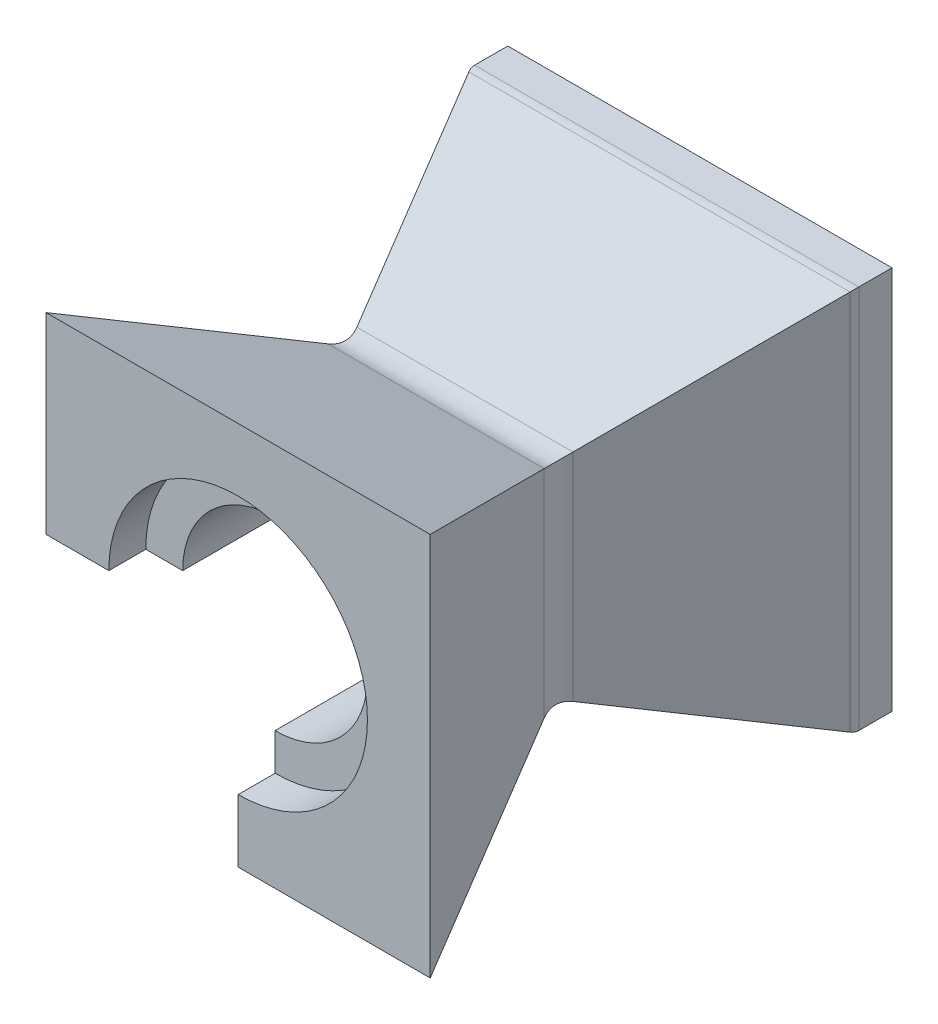
from build123d import *

# Parameters (mm, degrees)
SKETCH1_W           = 104
SKETCH1_H           = 104
SKETCH1_R           = 25
BOSS_EXTRUDE1_DEPTH = 115
CUT_EXTRUDE3_DEPTH  = 115
CUT_EXTRUDE4_DEPTH  = 115
CUT_EXTRUDE5_DEPTH  = 116
FILLET1_R           = 10
SKETCH9_R           = 35
CUT_EXTRUDE6_DEPTH  = 10
SKETCH10_R          = 35
CUT_EXTRUDE7_DEPTH  = 10
BOSS_EXTRUDE2_DEPTH = 10
FILLET2_R           = 5
CUT_EXTRUDE8_DEPTH  = 10


with BuildPart() as part:
    # Sketch1 → Boss-Extrude1 (new body)
    with BuildSketch(Plane.XY):
        Rectangle(SKETCH1_W, SKETCH1_H)
        Circle(SKETCH1_R, mode=Mode.SUBTRACT)
    extrude(amount=BOSS_EXTRUDE1_DEPTH)

    # Sketch7 → Cut-Extrude3 (cut)
    with BuildSketch(Plane.ZY.offset(52)):
        Polygon((0, 52), (115, 52), (57.5, 27.592698068), align=None)
        Polygon((0, -52), (115, -52), (57.5, -27.592698068), align=None)
    extrude(amount=-CUT_EXTRUDE3_DEPTH, mode=Mode.SUBTRACT)

    # Sketch4 → Cut-Extrude4 (cut)
    with BuildSketch(Plane(origin=(0, 52, 0), x_dir=(1, 0, 0), z_dir=(0, 1, 0))):
        Polygon((-52, 0), (-27.592698068, -57.5), (-52, -115), align=None)
        Polygon((52, -115), (27.592698068, -57.5), (52, 0), align=None)
    extrude(amount=-CUT_EXTRUDE4_DEPTH, mode=Mode.SUBTRACT)

    # Sketch8 → Cut-Extrude5 (cut, through all)
    with BuildSketch(Plane(origin=(0, 0, 0), x_dir=(-1, 0, 0), z_dir=(0, 0, -1))):
        with BuildLine():
            Line((0, 0), (96.389790508, 0))
            ThreePointArc((96.389790508, 0), (83.425867148, -83.299633305), (0, -95.424686222))
            Line((0, -95.424686222), (0, 0))
        make_face()
    extrude(amount=-CUT_EXTRUDE5_DEPTH, mode=Mode.SUBTRACT)

    # Fillet1
    fillet1_edges = [part.edges().sort_by_distance(p)[0] for p in [
        (13.796349034, -27.592698068, 57.5),
        (0, 27.592698068, 57.5),
        (27.592698068, 0, 57.5),
        (-27.592698068, 13.796349034, 57.5),
    ]]
    fillet(fillet1_edges, radius=FILLET1_R)

    # Sketch9 → Cut-Extrude6 (cut)
    with BuildSketch(Plane(origin=(0, 0, 0), x_dir=(-1, 0, 0), z_dir=(0, 0, -1))):
        Circle(SKETCH9_R)
    extrude(amount=-CUT_EXTRUDE6_DEPTH, mode=Mode.SUBTRACT)

    # Sketch10 → Cut-Extrude7 (cut)
    with BuildSketch(Plane.XY.offset(115)):
        Circle(SKETCH10_R)
    extrude(amount=-CUT_EXTRUDE7_DEPTH, mode=Mode.SUBTRACT)

    # Sketch11 → Boss-Extrude2 (add)
    with BuildSketch(Plane(origin=(0, 0, 0), x_dir=(-1, 0, 0), z_dir=(0, 0, -1))):
        Polygon((52, 0), (52, 52), (-52, 52), (-52, -52), (0, -52), (0, -49), (-49, -49), (-49, 49), (49, 49), (49, 0), align=None)
    extrude(amount=BOSS_EXTRUDE2_DEPTH)

    # Fillet2
    fillet2_edges = [part.edges().sort_by_distance(p)[0] for p in [
        (0, 52, 0),
        (52, 0, 0),
        (-52, 26, 0),
        (26, -52, 0),
    ]]
    fillet(fillet2_edges, radius=FILLET2_R)

    # Sketch12 → Cut-Extrude8 (cut)
    with BuildSketch(Plane(origin=(0, 0, 0), x_dir=(-1, 0, 0), z_dir=(0, 0, -1))):
        with BuildLine():
            Line((27.930717857, 32.173358544), (38.537319575, 42.779960262))
            ThreePointArc((38.537319575, 42.779960262), (42.779960262, 42.779960262), (42.779960262, 38.537319575))
            Line((42.779960262, 38.537319575), (32.173358544, 27.930717857))
            ThreePointArc((32.173358544, 27.930717857), (27.930717857, 27.930717857), (27.930717857, 32.173358544))
        make_face()
        with BuildLine():
            Line((-32.173358544, 27.930717857), (-42.779960262, 38.537319575))
            ThreePointArc((-42.779960262, 38.537319575), (-42.779960262, 42.779960262), (-38.537319575, 42.779960262))
            Line((-38.537319575, 42.779960262), (-27.930717857, 32.173358544))
            ThreePointArc((-27.930717857, 32.173358544), (-27.930717857, 27.930717857), (-32.173358544, 27.930717857))
        make_face()
        with BuildLine():
            Line((-27.930717857, -32.173358544), (-38.537319575, -42.779960262))
            ThreePointArc((-38.537319575, -42.779960262), (-42.779960262, -42.779960262), (-42.779960262, -38.537319575))
            Line((-42.779960262, -38.537319575), (-32.173358544, -27.930717857))
            ThreePointArc((-32.173358544, -27.930717857), (-27.930717857, -27.930717857), (-27.930717857, -32.173358544))
        make_face()
    extrude(amount=-CUT_EXTRUDE8_DEPTH, mode=Mode.SUBTRACT)


solid = part.part
